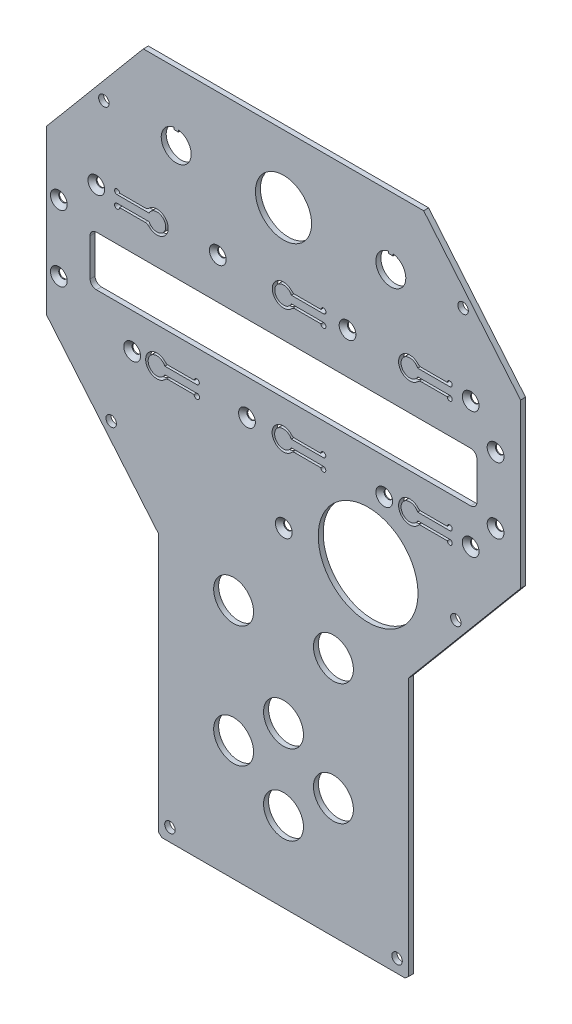
from build123d import *

# Parameters (mm, degrees)
RESSALTO_EXTRUS_O1_DEPTH                      = 2
CORTE_EXTRUS_O1_REACH                         = 4
ESBO_O2_R                                     = 2.1
CORTE_EXTRUS_O2_REACH                         = 4
CORTE_EXTRUS_O3_REACH                         = 4
ESBO_O4_R                                     = 20
CORTE_EXTRUS_O4_REACH                         = 4
ESBO_O5_R                                     = 8
ESBO_O5_R_2                                   = 11.25
ESCAREADO_PARA_PARAFUSO_ALLEN_SEXTAV_2_COUNT  = 2
ESCAREADO_PARA_PARAFUSO_ALLEN_SEXTAV_2_PITCH  = 26.5
ESCAREADO_PARA_PARAFUSO_ALLEN_SEXTAV_3_COUNT  = 2
ESCAREADO_PARA_PARAFUSO_ALLEN_SEXTAV_3_PITCH  = 47.918783057
ESCAREADO_PARA_PARAFUSO_ALLEN_SEXTAV_4_COUNT  = 2
ESCAREADO_PARA_PARAFUSO_ALLEN_SEXTAV_4_PITCH  = 84.354894452
ESCAREADO_PARA_PARAFUSO_ALLEN_SEXTAV_5_COUNT  = 2
ESCAREADO_PARA_PARAFUSO_ALLEN_SEXTAV_5_PITCH  = 135.769067452
ESCAREADO_PARA_PARAFUSO_ALLEN_SEXTAV_6_COUNT  = 2
ESCAREADO_PARA_PARAFUSO_ALLEN_SEXTAV_6_PITCH  = 176.995056428
ESCAREADO_PARA_PARAFUSO_ALLEN_SEXTAV_7_COUNT  = 2
ESCAREADO_PARA_PARAFUSO_ALLEN_SEXTAV_7_PITCH  = 175
ESCAREADO_PARA_PARAFUSO_ALLEN_SEXTAV_8_COUNT  = 2
ESCAREADO_PARA_PARAFUSO_ALLEN_SEXTAV_8_PITCH  = 116.384068539
ESCAREADO_PARA_PARAFUSO_ALLEN_SEXTAV_9_COUNT  = 2
ESCAREADO_PARA_PARAFUSO_ALLEN_SEXTAV_9_PITCH  = 64.945475466
ESCAREADO_PARA_PARAFUSO_ALLEN_SEXTAV_10_COUNT = 2
ESCAREADO_PARA_PARAFUSO_ALLEN_SEXTAV_10_PITCH = 113.39334618
CORTE_EXTRUS_O5_DEPTH                         = 10
FILETE1_R                                     = 2
ESCAREADO_PARA_PARAFUSO_ALLEN_SEXTAV_12_COUNT = 2
ESCAREADO_PARA_PARAFUSO_ALLEN_SEXTAV_12_PITCH = 150
ESCAREADO_PARA_PARAFUSO_ALLEN_SEXTAV_13_COUNT = 2
ESCAREADO_PARA_PARAFUSO_ALLEN_SEXTAV_13_PITCH = 158.297944738


with BuildPart() as part:
    # Esboço1 → Ressalto-extrusão1 (new body)
    with BuildSketch(Plane.XY):
        Polygon((55.321046002, 133.809611411), (-57.006999458, 133.809611411), (-95.842976728, 87.526695978), (-95.842976728, 22.140182404), (-50.842976728, -31.488729263), (-50.842976728, -135.082673958), (-49.522853837, -136.190388589), (47.836900381, -136.190388589), (49.157023272, -135.082673958), (49.157023272, -31.488729263), (94.157023272, 22.140182404), (94.157023272, 87.526695978), align=None)
    extrude(amount=RESSALTO_EXTRUS_O1_DEPTH)

    # Esboço2 → Corte-extrusão1 (cut, up to next)
    with BuildSketch(Plane.XY.offset(2), mode=Mode.PRIVATE) as corte_extrus_o1_sk1:
        with Locations((-72.814392548, 107.949888211)):
            Circle(ESBO_O2_R)
    corte_extrus_o1_tool1 = extrude(corte_extrus_o1_sk1.sketch, amount=-CORTE_EXTRUS_O1_REACH, mode=Mode.PRIVATE) & part.part
    add(corte_extrus_o1_tool1.solids().sort_by_distance((-72.814393, 107.949888, 2))[0], mode=Mode.SUBTRACT)
    # Esboço2 → Corte-extrusão1 (cut, up to next)
    with BuildSketch(Plane.XY.offset(2), mode=Mode.PRIVATE) as corte_extrus_o1_sk2:
        with Locations((-46.342976728, -130.964393909)):
            Circle(ESBO_O2_R)
    corte_extrus_o1_tool2 = extrude(corte_extrus_o1_sk2.sketch, amount=-CORTE_EXTRUS_O1_REACH, mode=Mode.PRIVATE) & part.part
    add(corte_extrus_o1_tool2.solids().sort_by_distance((-46.342977, -130.964394, 2))[0], mode=Mode.SUBTRACT)
    # Esboço2 → Corte-extrusão1 (cut, up to next)
    with BuildSketch(Plane.XY.offset(2), mode=Mode.PRIVATE) as corte_extrus_o1_sk3:
        with Locations((44.657023272, -130.964393909)):
            Circle(ESBO_O2_R)
    corte_extrus_o1_tool3 = extrude(corte_extrus_o1_sk3.sketch, amount=-CORTE_EXTRUS_O1_REACH, mode=Mode.PRIVATE) & part.part
    add(corte_extrus_o1_tool3.solids().sort_by_distance((44.657023, -130.964394, 2))[0], mode=Mode.SUBTRACT)
    # Esboço2 → Corte-extrusão1 (cut, up to next)
    with BuildSketch(Plane.XY.offset(2), mode=Mode.PRIVATE) as corte_extrus_o1_sk4:
        with Locations((71.128439092, 107.949888211)):
            Circle(ESBO_O2_R)
    corte_extrus_o1_tool4 = extrude(corte_extrus_o1_sk4.sketch, amount=-CORTE_EXTRUS_O1_REACH, mode=Mode.PRIVATE) & part.part
    add(corte_extrus_o1_tool4.solids().sort_by_distance((71.128439, 107.949888, 2))[0], mode=Mode.SUBTRACT)
    # Esboço2 → Corte-extrusão1 (cut, up to next)
    with BuildSketch(Plane.XY.offset(2), mode=Mode.PRIVATE) as corte_extrus_o1_sk5:
        with Locations((-69.895776734, -1.781729186)):
            Circle(ESBO_O2_R)
    corte_extrus_o1_tool5 = extrude(corte_extrus_o1_sk5.sketch, amount=-CORTE_EXTRUS_O1_REACH, mode=Mode.PRIVATE) & part.part
    add(corte_extrus_o1_tool5.solids().sort_by_distance((-69.895777, -1.781729, 2))[0], mode=Mode.SUBTRACT)
    # Esboço2 → Corte-extrusão1 (cut, up to next)
    with BuildSketch(Plane.XY.offset(2), mode=Mode.PRIVATE) as corte_extrus_o1_sk6:
        with Locations((68.209823278, -1.781729186)):
            Circle(ESBO_O2_R)
    corte_extrus_o1_tool6 = extrude(corte_extrus_o1_sk6.sketch, amount=-CORTE_EXTRUS_O1_REACH, mode=Mode.PRIVATE) & part.part
    add(corte_extrus_o1_tool6.solids().sort_by_distance((68.209823, -1.781729, 2))[0], mode=Mode.SUBTRACT)

    # Esboço3 → Corte-extrusão2 (cut, up to next)
    with BuildSketch(Plane.XY.offset(2), mode=Mode.PRIVATE) as corte_extrus_o2_sk1:
        with BuildLine():
            Line((-75.842976728, 40.809611411), (74.157023272, 40.809611411))
            ThreePointArc((74.157023272, 40.809611411), (75.924790225, 41.541844458), (76.657023272, 43.309611411))
            Line((76.657023272, 43.309611411), (76.657023272, 58.309611411))
            ThreePointArc((76.657023272, 58.309611411), (75.924790225, 60.077378364), (74.157023272, 60.809611411))
            Line((74.157023272, 60.809611411), (-75.842976728, 60.809611411))
            ThreePointArc((-75.842976728, 60.809611411), (-77.610743681, 60.077378364), (-78.342976728, 58.309611411))
            Line((-78.342976728, 58.309611411), (-78.342976728, 43.309611411))
            ThreePointArc((-78.342976728, 43.309611411), (-77.610743681, 41.541844458), (-75.842976728, 40.809611411))
        make_face()
    corte_extrus_o2_tool1 = extrude(corte_extrus_o2_sk1.sketch, amount=-CORTE_EXTRUS_O2_REACH, mode=Mode.PRIVATE) & part.part
    add(corte_extrus_o2_tool1.solids().sort_by_distance((-0.842977, 50.809611, 2))[0], mode=Mode.SUBTRACT)

    # Esboço4 → Corte-extrusão3 (cut, up to next)
    with BuildSketch(Plane.XY.offset(2), mode=Mode.PRIVATE) as corte_extrus_o3_sk1:
        with Locations((33.056325833, -0.190388589)):
            Circle(ESBO_O4_R)
    corte_extrus_o3_tool1 = extrude(corte_extrus_o3_sk1.sketch, amount=-CORTE_EXTRUS_O3_REACH, mode=Mode.PRIVATE) & part.part
    add(corte_extrus_o3_tool1.solids().sort_by_distance((33.056326, -0.190389, 2))[0], mode=Mode.SUBTRACT)

    # Esboço5 → Corte-extrusão4 (cut, up to next)
    with BuildSketch(Plane.XY.offset(2), mode=Mode.PRIVATE) as corte_extrus_o4_sk1:
        with Locations((-20.842976728, -88.105888589)):
            Circle(ESBO_O5_R)
    corte_extrus_o4_tool1 = extrude(corte_extrus_o4_sk1.sketch, amount=-CORTE_EXTRUS_O4_REACH, mode=Mode.PRIVATE) & part.part
    add(corte_extrus_o4_tool1.solids().sort_by_distance((-20.842977, -88.105889, 2))[0], mode=Mode.SUBTRACT)
    # Esboço5 → Corte-extrusão4 (cut, up to next)
    with BuildSketch(Plane.XY.offset(2), mode=Mode.PRIVATE) as corte_extrus_o4_sk2:
        with Locations((19.157023272, -88.105888589)):
            Circle(ESBO_O5_R)
    corte_extrus_o4_tool2 = extrude(corte_extrus_o4_sk2.sketch, amount=-CORTE_EXTRUS_O4_REACH, mode=Mode.PRIVATE) & part.part
    add(corte_extrus_o4_tool2.solids().sort_by_distance((19.157023, -88.105889, 2))[0], mode=Mode.SUBTRACT)
    # Esboço5 → Corte-extrusão4 (cut, up to next)
    with BuildSketch(Plane.XY.offset(2), mode=Mode.PRIVATE) as corte_extrus_o4_sk3:
        with Locations((-0.842976728, -104.141188589)):
            Circle(ESBO_O5_R)
    corte_extrus_o4_tool3 = extrude(corte_extrus_o4_sk3.sketch, amount=-CORTE_EXTRUS_O4_REACH, mode=Mode.PRIVATE) & part.part
    add(corte_extrus_o4_tool3.solids().sort_by_distance((-0.842977, -104.141189, 2))[0], mode=Mode.SUBTRACT)
    # Esboço5 → Corte-extrusão4 (cut, up to next)
    with BuildSketch(Plane.XY.offset(2), mode=Mode.PRIVATE) as corte_extrus_o4_sk4:
        with Locations((-0.842976728, -72.123388589)):
            Circle(ESBO_O5_R)
    corte_extrus_o4_tool4 = extrude(corte_extrus_o4_sk4.sketch, amount=-CORTE_EXTRUS_O4_REACH, mode=Mode.PRIVATE) & part.part
    add(corte_extrus_o4_tool4.solids().sort_by_distance((-0.842977, -72.123389, 2))[0], mode=Mode.SUBTRACT)
    # Esboço5 → Corte-extrusão4 (cut, up to next)
    with BuildSketch(Plane.XY.offset(2), mode=Mode.PRIVATE) as corte_extrus_o4_sk5:
        with Locations((-20.842976728, -39.520254174)):
            Circle(ESBO_O5_R)
    corte_extrus_o4_tool5 = extrude(corte_extrus_o4_sk5.sketch, amount=-CORTE_EXTRUS_O4_REACH, mode=Mode.PRIVATE) & part.part
    add(corte_extrus_o4_tool5.solids().sort_by_distance((-20.842977, -39.520254, 2))[0], mode=Mode.SUBTRACT)
    # Esboço5 → Corte-extrusão4 (cut, up to next)
    with BuildSketch(Plane.XY.offset(2), mode=Mode.PRIVATE) as corte_extrus_o4_sk6:
        with Locations((19.157023272, -39.520254174)):
            Circle(ESBO_O5_R)
    corte_extrus_o4_tool6 = extrude(corte_extrus_o4_sk6.sketch, amount=-CORTE_EXTRUS_O4_REACH, mode=Mode.PRIVATE) & part.part
    add(corte_extrus_o4_tool6.solids().sort_by_distance((19.157023, -39.520254, 2))[0], mode=Mode.SUBTRACT)
    # Esboço5 → Corte-extrusão4 (cut, up to next)
    with BuildSketch(Plane.XY.offset(2), mode=Mode.PRIVATE) as corte_extrus_o4_sk7:
        with Locations((-0.842976728, 106.809611411)):
            Circle(ESBO_O5_R_2)
    corte_extrus_o4_tool7 = extrude(corte_extrus_o4_sk7.sketch, amount=-CORTE_EXTRUS_O4_REACH, mode=Mode.PRIVATE) & part.part
    add(corte_extrus_o4_tool7.solids().sort_by_distance((-0.842977, 106.809611, 2))[0], mode=Mode.SUBTRACT)
    # Esboço5 → Corte-extrusão4 (cut, up to next)
    with BuildSketch(Plane.XY.offset(2), mode=Mode.PRIVATE) as corte_extrus_o4_sk8:
        with BuildLine():
            Line((-44.742976728, 112.741727391), (-44.742976728, 111.941727391))
            Line((-44.742976728, 111.941727391), (-42.942976728, 111.941727391))
            Line((-42.942976728, 111.941727391), (-42.942976728, 112.741727391))
            ThreePointArc((-42.942976728, 112.741727391), (-43.842976728, 100.809611411), (-44.742976728, 112.741727391))
        make_face()
    corte_extrus_o4_tool8 = extrude(corte_extrus_o4_sk8.sketch, amount=-CORTE_EXTRUS_O4_REACH, mode=Mode.PRIVATE) & part.part
    add(corte_extrus_o4_tool8.solids().sort_by_distance((-43.842977, 106.733858, 2))[0], mode=Mode.SUBTRACT)
    # Esboço5 → Corte-extrusão4 (cut, up to next)
    with BuildSketch(Plane.XY.offset(2), mode=Mode.PRIVATE) as corte_extrus_o4_sk9:
        with BuildLine():
            Line((41.257023272, 112.741727391), (41.257023272, 111.941727391))
            Line((41.257023272, 111.941727391), (43.057023272, 111.941727391))
            Line((43.057023272, 111.941727391), (43.057023272, 112.741727391))
            ThreePointArc((43.057023272, 112.741727391), (42.157023272, 100.809611411), (41.257023272, 112.741727391))
        make_face()
    corte_extrus_o4_tool9 = extrude(corte_extrus_o4_sk9.sketch, amount=-CORTE_EXTRUS_O4_REACH, mode=Mode.PRIVATE) & part.part
    add(corte_extrus_o4_tool9.solids().sort_by_distance((42.157023, 106.733858, 2))[0], mode=Mode.SUBTRACT)

    # Esboço11 → Escareado para parafuso Allen sextavado (revolve, cut)
    with BuildSketch(Plane(origin=(-90.868976728, 64.471011411, 2), x_dir=(0, -1, 0), z_dir=(1, 0, 0))):
        Polygon((0, 0), (0, 2), (1.7, 2), (1.7, 1.66), (3.36, 0), align=None)
    escareado_para_parafuso_allen_sextavado = revolve(axis=Axis((-90.868976728, 64.471011411, 8.35), (0, 0, -1)), mode=Mode.SUBTRACT)

    # Escareado para parafuso Allen sextav 2: Escareado para parafuso Allen sextavado ×2
    with Locations(*[(0, -i * ESCAREADO_PARA_PARAFUSO_ALLEN_SEXTAV_2_PITCH, 0) for i in range(1, ESCAREADO_PARA_PARAFUSO_ALLEN_SEXTAV_2_COUNT)]):
        add(escareado_para_parafuso_allen_sextavado, mode=Mode.SUBTRACT)

    # Escareado para parafuso Allen sextav 3: Escareado para parafuso Allen sextavado ×2
    with Locations(*[Vector(0.613251976, -0.789887343, 0) * (i * ESCAREADO_PARA_PARAFUSO_ALLEN_SEXTAV_3_PITCH) for i in range(1, ESCAREADO_PARA_PARAFUSO_ALLEN_SEXTAV_3_COUNT)]):
        add(escareado_para_parafuso_allen_sextavado, mode=Mode.SUBTRACT)

    # Escareado para parafuso Allen sextav 4: Escareado para parafuso Allen sextavado ×2
    with Locations(*[Vector(0.893680068, -0.448704731, 0) * (i * ESCAREADO_PARA_PARAFUSO_ALLEN_SEXTAV_4_PITCH) for i in range(1, ESCAREADO_PARA_PARAFUSO_ALLEN_SEXTAV_4_COUNT)]):
        add(escareado_para_parafuso_allen_sextavado, mode=Mode.SUBTRACT)

    # Escareado para parafuso Allen sextav 5: Escareado para parafuso Allen sextavado ×2
    with Locations(*[Vector(0.960353411, -0.278785447, 0) * (i * ESCAREADO_PARA_PARAFUSO_ALLEN_SEXTAV_5_PITCH) for i in range(1, ESCAREADO_PARA_PARAFUSO_ALLEN_SEXTAV_5_COUNT)]):
        add(escareado_para_parafuso_allen_sextavado, mode=Mode.SUBTRACT)

    # Escareado para parafuso Allen sextav 6: Escareado para parafuso Allen sextavado ×2
    with Locations(*[Vector(0.98872818, -0.149721696, 0) * (i * ESCAREADO_PARA_PARAFUSO_ALLEN_SEXTAV_6_PITCH) for i in range(1, ESCAREADO_PARA_PARAFUSO_ALLEN_SEXTAV_6_COUNT)]):
        add(escareado_para_parafuso_allen_sextavado, mode=Mode.SUBTRACT)

    # Escareado para parafuso Allen sextav 7: Escareado para parafuso Allen sextavado ×2
    with Locations(*[(i * ESCAREADO_PARA_PARAFUSO_ALLEN_SEXTAV_7_PITCH, 0, 0) for i in range(1, ESCAREADO_PARA_PARAFUSO_ALLEN_SEXTAV_7_COUNT)]):
        add(escareado_para_parafuso_allen_sextavado, mode=Mode.SUBTRACT)

    # Escareado para parafuso Allen sextav 8: Escareado para parafuso Allen sextavado ×2
    with Locations(*[Vector(0.994001416, 0.109367203, 0) * (i * ESCAREADO_PARA_PARAFUSO_ALLEN_SEXTAV_8_PITCH) for i in range(1, ESCAREADO_PARA_PARAFUSO_ALLEN_SEXTAV_8_COUNT)]):
        add(escareado_para_parafuso_allen_sextavado, mode=Mode.SUBTRACT)

    # Escareado para parafuso Allen sextav 9: Escareado para parafuso Allen sextavado ×2
    with Locations(*[Vector(0.98060609, 0.195989019, 0) * (i * ESCAREADO_PARA_PARAFUSO_ALLEN_SEXTAV_9_PITCH) for i in range(1, ESCAREADO_PARA_PARAFUSO_ALLEN_SEXTAV_9_COUNT)]):
        add(escareado_para_parafuso_allen_sextavado, mode=Mode.SUBTRACT)

    # Escareado para parafuso Allen sextav 10: Escareado para parafuso Allen sextavado ×2
    with Locations(*[Vector(0.794899268, -0.606741423, 0) * (i * ESCAREADO_PARA_PARAFUSO_ALLEN_SEXTAV_10_PITCH) for i in range(1, ESCAREADO_PARA_PARAFUSO_ALLEN_SEXTAV_10_COUNT)]):
        add(escareado_para_parafuso_allen_sextavado, mode=Mode.SUBTRACT)

    # Esboço12 → Corte-extrusão5 (cut)
    with BuildSketch(Plane.XY.offset(2)):
        with BuildLine():
            Line((52.929300932, 28.019611411), (65.767023272, 28.019611411))
            ThreePointArc((65.767023272, 28.019611411), (66.474130053, 29.726718193), (64.767023272, 29.019611411))
            Line((64.767023272, 29.019611411), (53.508680659, 29.019611411))
            ThreePointArc((53.508680659, 29.019611411), (45.267023272, 26.519611411), (53.508680659, 24.019611411))
            Line((53.508680659, 24.019611411), (64.767023272, 24.019611411))
            ThreePointArc((64.767023272, 24.019611411), (66.474130053, 23.31250463), (65.767023272, 25.019611411))
            Line((65.767023272, 25.019611411), (52.929300932, 25.019611411))
            ThreePointArc((52.929300932, 25.019611411), (46.267023272, 26.519611411), (52.929300932, 28.019611411))
        make_face()
        with BuildLine():
            Line((2.259300932, 28.019611411), (15.097023272, 28.019611411))
            ThreePointArc((15.097023272, 28.019611411), (15.804130053, 29.726718193), (14.097023272, 29.019611411))
            Line((14.097023272, 29.019611411), (2.838680659, 29.019611411))
            ThreePointArc((2.838680659, 29.019611411), (-5.402976728, 26.519611411), (2.838680659, 24.019611411))
            Line((2.838680659, 24.019611411), (14.097023272, 24.019611411))
            ThreePointArc((14.097023272, 24.019611411), (15.804130053, 23.31250463), (15.097023272, 25.019611411))
            Line((15.097023272, 25.019611411), (2.259300932, 25.019611411))
            ThreePointArc((2.259300932, 25.019611411), (-4.402976728, 26.519611411), (2.259300932, 28.019611411))
        make_face()
        with BuildLine():
            Line((-48.410699068, 28.019611411), (-35.572976728, 28.019611411))
            ThreePointArc((-35.572976728, 28.019611411), (-34.865869947, 29.726718193), (-36.572976728, 29.019611411))
            Line((-36.572976728, 29.019611411), (-47.831319341, 29.019611411))
            ThreePointArc((-47.831319341, 29.019611411), (-56.072976728, 26.519611411), (-47.831319341, 24.019611411))
            Line((-47.831319341, 24.019611411), (-36.653425887, 24.019611411))
            ThreePointArc((-36.653425887, 24.019611411), (-34.675928196, 23.417386939), (-35.982085986, 25.019611411))
            Line((-35.982085986, 25.019611411), (-48.410699068, 25.019611411))
            ThreePointArc((-48.410699068, 25.019611411), (-55.072976728, 26.519611411), (-48.410699068, 28.019611411))
        make_face()
        with BuildLine():
            Line((2.329300932, 77.979611411), (15.167023272, 77.979611411))
            ThreePointArc((15.167023272, 77.979611411), (15.874130053, 79.686718193), (14.167023272, 78.979611411))
            Line((14.167023272, 78.979611411), (2.908680659, 78.979611411))
            ThreePointArc((2.908680659, 78.979611411), (-5.332976728, 76.479611411), (2.908680659, 73.979611411))
            Line((2.908680659, 73.979611411), (14.167023272, 73.979611411))
            ThreePointArc((14.167023272, 73.979611411), (15.874130053, 73.27250463), (15.167023272, 74.979611411))
            Line((15.167023272, 74.979611411), (2.329300932, 74.979611411))
            ThreePointArc((2.329300932, 74.979611411), (-4.332976728, 76.479611411), (2.329300932, 77.979611411))
        make_face()
        with BuildLine():
            Line((52.929300932, 77.979611411), (65.767023272, 77.979611411))
            ThreePointArc((65.767023272, 77.979611411), (66.474130053, 79.686718193), (64.767023272, 78.979611411))
            Line((64.767023272, 78.979611411), (53.508680659, 78.979611411))
            ThreePointArc((53.508680659, 78.979611411), (45.267023272, 76.479611411), (53.508680659, 73.979611411))
            Line((53.508680659, 73.979611411), (64.767023272, 73.979611411))
            ThreePointArc((64.767023272, 73.979611411), (66.474130053, 73.27250463), (65.767023272, 74.979611411))
            Line((65.767023272, 74.979611411), (52.929300932, 74.979611411))
            ThreePointArc((52.929300932, 74.979611411), (46.267023272, 76.479611411), (52.929300932, 77.979611411))
        make_face()
        with BuildLine():
            Line((-54.695254388, 77.979611411), (-67.532976728, 77.979611411))
            ThreePointArc((-67.532976728, 77.979611411), (-68.240083509, 79.686718193), (-66.532976728, 78.979611411))
            Line((-66.532976728, 78.979611411), (-55.274634115, 78.979611411))
            ThreePointArc((-55.274634115, 78.979611411), (-47.032976728, 76.479611411), (-55.274634115, 73.979611411))
            Line((-55.274634115, 73.979611411), (-66.532976728, 73.979611411))
            ThreePointArc((-66.532976728, 73.979611411), (-68.240083509, 73.27250463), (-67.532976728, 74.979611411))
            Line((-67.532976728, 74.979611411), (-54.695254388, 74.979611411))
            ThreePointArc((-54.695254388, 74.979611411), (-48.032976728, 76.479611411), (-54.695254388, 77.979611411))
        make_face()
    extrude(amount=-CORTE_EXTRUS_O5_DEPTH, mode=Mode.SUBTRACT)

    # Filete1
    filete1_edges = [part.edges().sort_by_distance(p)[0] for p in [
        (53.508680659, 29.019611411, 1),
        (-47.831319341, 24.019611411, 1),
        (-47.831319341, 29.019611411, 1),
        (-55.274634115, 78.979611411, 1),
        (-55.274634115, 73.979611411, 1),
        (2.908680659, 73.979611411, 1),
        (2.908680659, 78.979611411, 1),
        (53.508680659, 73.979611411, 1),
        (53.508680659, 78.979611411, 1),
        (2.838680659, 24.019611411, 1),
        (2.838680659, 29.019611411, 1),
    ]]
    fillet(filete1_edges, radius=FILETE1_R)

    # Esboço14 → Escareado para parafuso Allen sextav 11 (revolve, cut)
    with BuildSketch(Plane(origin=(-75.842976728, 77.199611411, 2), x_dir=(0, -1, 0), z_dir=(1, 0, 0))):
        Polygon((0, 0), (0, 2), (1.7, 2), (1.7, 1.66), (3.36, 0), align=None)
    escareado_para_parafuso_allen_sextav_11 = revolve(axis=Axis((-75.842976728, 77.199611411, 8.35), (0, 0, -1)), mode=Mode.SUBTRACT)

    # Escareado para parafuso Allen sextav 12: Escareado para parafuso Allen sextav 11 ×2
    with Locations(*[(i * ESCAREADO_PARA_PARAFUSO_ALLEN_SEXTAV_12_PITCH, 0, 0) for i in range(1, ESCAREADO_PARA_PARAFUSO_ALLEN_SEXTAV_12_COUNT)]):
        add(escareado_para_parafuso_allen_sextav_11, mode=Mode.SUBTRACT)

    # Escareado para parafuso Allen sextav 13: Escareado para parafuso Allen sextav 11 ×2
    with Locations(*[Vector(0.947580212, -0.319517984, 0) * (i * ESCAREADO_PARA_PARAFUSO_ALLEN_SEXTAV_13_PITCH) for i in range(1, ESCAREADO_PARA_PARAFUSO_ALLEN_SEXTAV_13_COUNT)]):
        add(escareado_para_parafuso_allen_sextav_11, mode=Mode.SUBTRACT)


solid = part.part
